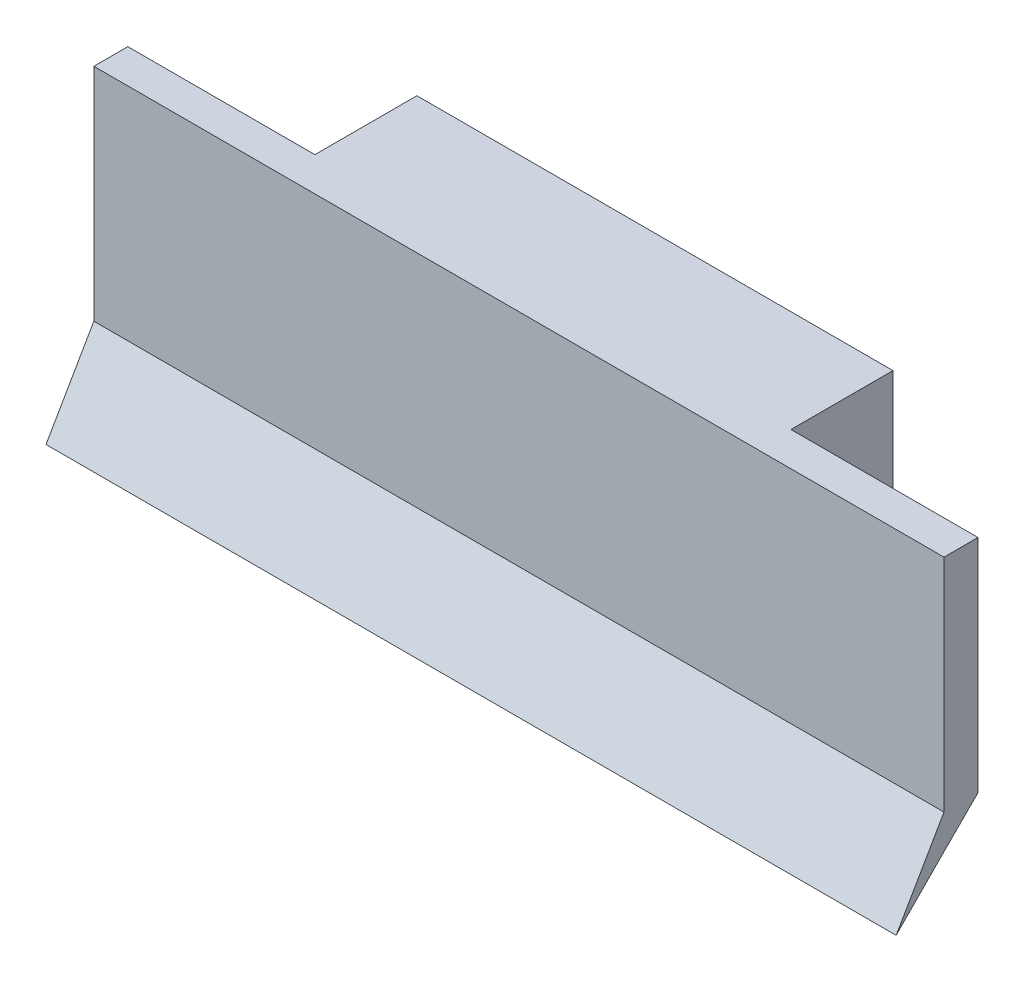
from build123d import *

# Parameters (mm, degrees)
BOSS_EXTRUDE1_DEPTH = 50
CUT_EXTRUDE1_DEPTH  = 11
BOSS_EXTRUDE2_DEPTH = 50


with BuildPart() as part:
    # Sketch1 → Boss-Extrude1 (new body)
    with BuildSketch(Plane(origin=(0, 0, 0), x_dir=(0, 0, -1), z_dir=(1, 0, 0))):
        Polygon((-28.922236088, -13.479594195), (-28.922236088, 1.520405805), (-20.922236088, 1.520405805), (-20.922236088, -5.479594195), align=None)
    extrude(amount=BOSS_EXTRUDE1_DEPTH)

    # Sketch2 → Cut-Extrude1 (cut)
    with BuildSketch(Plane(origin=(50, 0, 0), x_dir=(0, 0, -1), z_dir=(1, 0, 0))):
        Polygon((-20.922236088, 1.520405805), (-26.922236088, 1.520405805), (-26.922236088, -11.479594195), (-20.922236088, -5.479594195), align=None)
    cut_extrude1 = extrude(amount=-CUT_EXTRUDE1_DEPTH, mode=Mode.SUBTRACT)

    # Mirror1: Cut-Extrude1 across plane
    add(cut_extrude1.mirror(Plane(origin=(25, 0, 0), x_dir=(0, 0, 1), z_dir=(1, 0, 0))), mode=Mode.SUBTRACT)

    # Sketch3 → Boss-Extrude2 (add, through all)
    with BuildSketch(Plane(origin=(50, 0, 0), x_dir=(0, 0, -1), z_dir=(1, 0, 0))):
        Polygon((-28.922236088, -13.479594195), (-31.735625087, -16.337129199), (-28.922236088, -11.464196511), align=None)
    extrude(amount=-BOSS_EXTRUDE2_DEPTH)


solid = part.part
